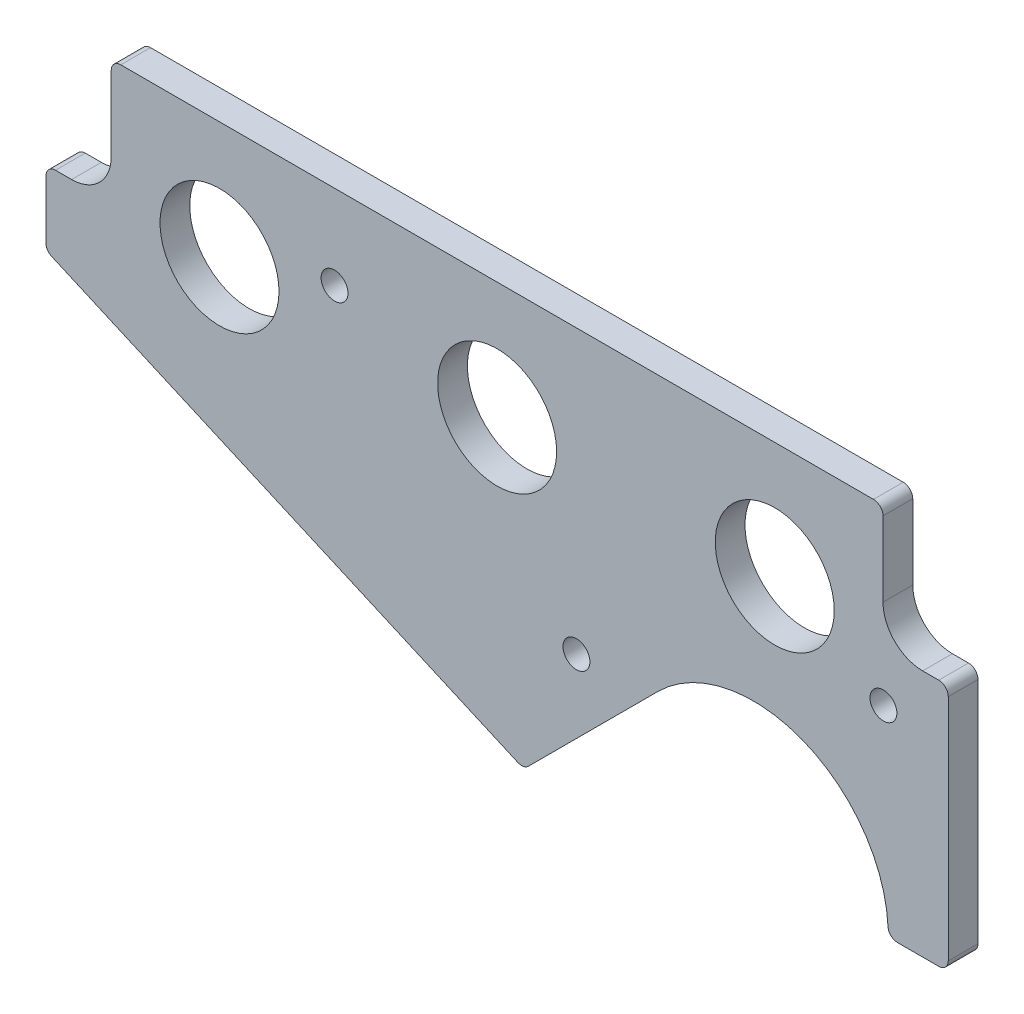
from build123d import *

# Parameters (mm, degrees)
BOSS_EXTRUDE1_DEPTH   = 4.7625
F_6_CLEARANCE_HOLE1_D = 4.3053
SKETCH5_R             = 9.525
CUT_EXTRUDE1_DEPTH    = 5.7625


with BuildPart() as part:
    # Sketch1 → Boss-Extrude1 (new body)
    with BuildSketch(Plane.XY.offset(-34.431186078)):
        with BuildLine():
            Line((-842.127056947, 5946.106287623), (-962.650056947, 5946.106287623))
            ThreePointArc((-962.650056947, 5946.106287623), (-963.727687681, 5945.659918357), (-964.174056947, 5944.582287623))
            Line((-964.174056947, 5944.582287623), (-964.174056947, 5932.612537623))
            ThreePointArc((-964.174056947, 5932.612537623), (-966.033928886, 5928.122409562), (-970.524056947, 5926.262537623))
            Line((-970.524056947, 5926.262537623), (-973.095806947, 5926.262537623))
            ThreePointArc((-973.095806947, 5926.262537623), (-974.173437681, 5925.816168357), (-974.619806947, 5924.738537623))
            Line((-974.619806947, 5924.738537623), (-974.619806947, 5915.392415905))
            ThreePointArc((-974.619806947, 5915.392415905), (-974.372123334, 5914.559593907), (-973.709580595, 5913.997475796))
            Line((-973.709580595, 5913.997475796), (-899.073125038, 5881.157435351))
            ThreePointArc((-899.073125038, 5881.157435351), (-898.178349327, 5881.054505693), (-897.381720655, 5881.474744726))
            Line((-897.381720655, 5881.474744726), (-876.633992352, 5902.222473029))
            ThreePointArc((-876.633992352, 5902.222473029), (-853.601284124, 5907.100841083), (-839.803970731, 5888.023674985))
            ThreePointArc((-839.803970731, 5888.023674985), (-839.332483448, 5886.99508367), (-838.281835234, 5886.575037623))
            Line((-838.281835234, 5886.575037623), (-831.681306947, 5886.575037623))
            ThreePointArc((-831.681306947, 5886.575037623), (-830.603676212, 5887.021406888), (-830.157306947, 5888.099037623))
            Line((-830.157306947, 5888.099037623), (-830.157306947, 5924.738537623))
            ThreePointArc((-830.157306947, 5924.738537623), (-830.603676212, 5925.816168357), (-831.681306947, 5926.262537623))
            Line((-831.681306947, 5926.262537623), (-834.253056947, 5926.262537623))
            ThreePointArc((-834.253056947, 5926.262537623), (-838.743185007, 5928.122409562), (-840.603056947, 5932.612537623))
            Line((-840.603056947, 5932.612537623), (-840.603056947, 5944.582287623))
            ThreePointArc((-840.603056947, 5944.582287623), (-841.049426212, 5945.659918357), (-842.127056947, 5946.106287623))
        make_face()
    extrude(amount=BOSS_EXTRUDE1_DEPTH)

    # #6 Clearance Hole1 (through all)
    with Locations(Plane.XY.offset(-29.668686078)):
        with Locations((-840.539556947, 5918.325037623), (-889.688556947, 5900.862537623), (-928.423556947, 5932.612537623)):
            Hole(F_6_CLEARANCE_HOLE1_D / 2)

    # Sketch5 → Cut-Extrude1 (cut, through all)
    with BuildSketch(Plane.XY.offset(-29.668686078)):
        with Locations((-857.938556947, 5927.524153596)):
            Circle(SKETCH5_R)
        with Locations((-902.388556947, 5927.342037623)):
            Circle(SKETCH5_R)
        with Locations((-946.838556947, 5927.342037623)):
            Circle(SKETCH5_R)
    extrude(amount=-CUT_EXTRUDE1_DEPTH, mode=Mode.SUBTRACT)


solid = part.part
